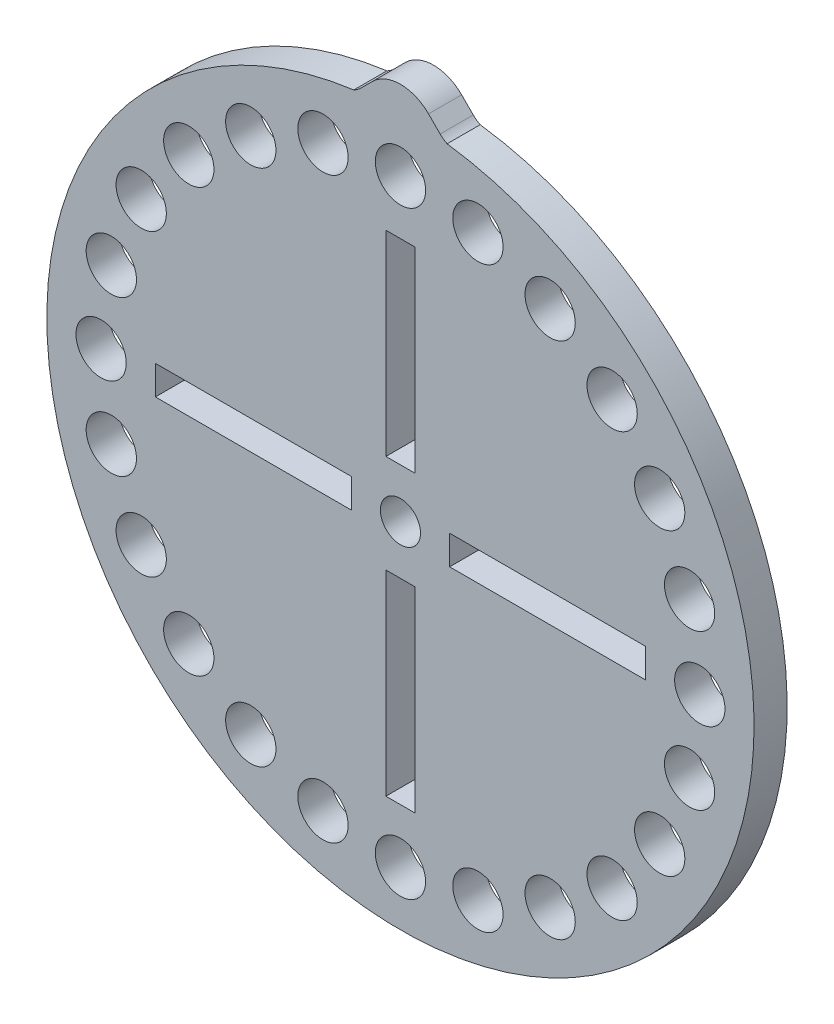
from build123d import *

# Parameters (mm, degrees)
SKETCH1_R             = 33.8
SKETCH1_R_2           = 2.54
SKETCH1_R_3           = 2.05
SKETCH1_W             = 3.048
SKETCH1_H             = 19.05
SKETCH1_W_2           = 19.05
SKETCH1_H_2           = 3.048
BOSS_EXTRUDE1_DEPTH   = 3.175
BOSS_EXTRUDE2_DEPTH   = 3.175
FILLET1_R             = 2.54
SKETCH4_R             = 33.927
SKETCH4_R_2           = 2.413
SKETCH4_R_3           = 1.923
SKETCH4_W             = 2.794
SKETCH4_H             = 18.796
SKETCH4_W_2           = 18.796
SKETCH4_H_2           = 2.794
KERF_ADJUSTMENT_DEPTH = 3.175


with BuildPart() as part:
    # Sketch1 → Boss-Extrude1 (new body)
    with BuildSketch(Plane.XY):
        Circle(SKETCH1_R)
        with Locations((14.36, 24.872249597)):
            Circle(SKETCH1_R_2, mode=Mode.SUBTRACT)
        with Locations((20.308106756, 20.308106756)):
            Circle(SKETCH1_R_2, mode=Mode.SUBTRACT)
        with Locations((24.872249597, 14.36)):
            Circle(SKETCH1_R_2, mode=Mode.SUBTRACT)
        with Locations((27.741389731, 7.433282975)):
            Circle(SKETCH1_R_2, mode=Mode.SUBTRACT)
        with Locations((28.72, 0)):
            Circle(SKETCH1_R_2, mode=Mode.SUBTRACT)
        with Locations((27.741389731, -7.433282975)):
            Circle(SKETCH1_R_2, mode=Mode.SUBTRACT)
        with Locations((24.872249597, -14.36)):
            Circle(SKETCH1_R_2, mode=Mode.SUBTRACT)
        with Locations((20.308106756, -20.308106756)):
            Circle(SKETCH1_R_2, mode=Mode.SUBTRACT)
        with Locations((14.36, -24.872249597)):
            Circle(SKETCH1_R_2, mode=Mode.SUBTRACT)
        with Locations((7.433282975, -27.741389731)):
            Circle(SKETCH1_R_2, mode=Mode.SUBTRACT)
        with Locations((0, -28.72)):
            Circle(SKETCH1_R_2, mode=Mode.SUBTRACT)
        with Locations((-7.433282975, -27.741389731)):
            Circle(SKETCH1_R_2, mode=Mode.SUBTRACT)
        with Locations((-14.36, -24.872249597)):
            Circle(SKETCH1_R_2, mode=Mode.SUBTRACT)
        with Locations((-20.308106756, -20.308106756)):
            Circle(SKETCH1_R_2, mode=Mode.SUBTRACT)
        with Locations((-24.872249597, -14.36)):
            Circle(SKETCH1_R_2, mode=Mode.SUBTRACT)
        with Locations((-27.741389731, -7.433282975)):
            Circle(SKETCH1_R_2, mode=Mode.SUBTRACT)
        with Locations((-28.72, 0)):
            Circle(SKETCH1_R_2, mode=Mode.SUBTRACT)
        with Locations((-27.741389731, 7.433282975)):
            Circle(SKETCH1_R_2, mode=Mode.SUBTRACT)
        with Locations((-24.872249597, 14.36)):
            Circle(SKETCH1_R_2, mode=Mode.SUBTRACT)
        with Locations((-20.308106756, 20.308106756)):
            Circle(SKETCH1_R_2, mode=Mode.SUBTRACT)
        with Locations((-14.36, 24.872249597)):
            Circle(SKETCH1_R_2, mode=Mode.SUBTRACT)
        with Locations((-7.433282975, 27.741389731)):
            Circle(SKETCH1_R_2, mode=Mode.SUBTRACT)
        with Locations((0, 28.72)):
            Circle(SKETCH1_R_2, mode=Mode.SUBTRACT)
        with Locations((7.433282975, 27.741389731)):
            Circle(SKETCH1_R_2, mode=Mode.SUBTRACT)
        Circle(SKETCH1_R_3, mode=Mode.SUBTRACT)
        with Locations((0, 14.115)):
            Rectangle(SKETCH1_W, SKETCH1_H, mode=Mode.SUBTRACT)
        with Locations((14.115, 0)):
            Rectangle(SKETCH1_W_2, SKETCH1_H_2, mode=Mode.SUBTRACT)
        with Locations((0, -14.115)):
            Rectangle(SKETCH1_W, SKETCH1_H, mode=Mode.SUBTRACT)
        with Locations((-14.115, 0)):
            Rectangle(SKETCH1_W_2, SKETCH1_H_2, mode=Mode.SUBTRACT)
    extrude(amount=BOSS_EXTRUDE1_DEPTH)

    # Sketch3 → Boss-Extrude2 (add)
    with BuildSketch(Plane.XY):
        with BuildLine():
            Line((-2.694076836, 35.224076836), (-4.406640425, 33.511513248))
            ThreePointArc((-4.406640425, 33.511513248), (0, 33.8), (4.406640425, 33.511513248))
            Line((4.406640425, 33.511513248), (2.694076836, 35.224076836))
            ThreePointArc((2.694076836, 35.224076836), (0, 36.34), (-2.694076836, 35.224076836))
        make_face()
    extrude(amount=BOSS_EXTRUDE2_DEPTH)

    # Fillet1
    fillet1_edges = [part.edges().sort_by_distance(p)[0] for p in [
        (-4.406640425, 33.511513248, 1.5875),
        (4.406640425, 33.511513248, 1.5875),
    ]]
    fillet(fillet1_edges, radius=FILLET1_R)

    # Sketch4 → Kerf Adjustment (add)
    with BuildSketch(Plane.XY):
        Circle(SKETCH4_R)
        with Locations((28.72, 0)):
            Circle(SKETCH4_R_2, mode=Mode.SUBTRACT)
        with Locations((27.741389731, 7.433282975)):
            Circle(SKETCH4_R_2, mode=Mode.SUBTRACT)
        with Locations((24.872249597, 14.36)):
            Circle(SKETCH4_R_2, mode=Mode.SUBTRACT)
        with Locations((20.308106756, 20.308106756)):
            Circle(SKETCH4_R_2, mode=Mode.SUBTRACT)
        with Locations((-14.36, -24.872249597)):
            Circle(SKETCH4_R_2, mode=Mode.SUBTRACT)
        with Locations((-7.433282975, -27.741389731)):
            Circle(SKETCH4_R_2, mode=Mode.SUBTRACT)
        with Locations((0, -28.72)):
            Circle(SKETCH4_R_2, mode=Mode.SUBTRACT)
        with Locations((7.433282975, -27.741389731)):
            Circle(SKETCH4_R_2, mode=Mode.SUBTRACT)
        with Locations((14.36, -24.872249597)):
            Circle(SKETCH4_R_2, mode=Mode.SUBTRACT)
        with Locations((20.308106756, -20.308106756)):
            Circle(SKETCH4_R_2, mode=Mode.SUBTRACT)
        with Locations((24.872249597, -14.36)):
            Circle(SKETCH4_R_2, mode=Mode.SUBTRACT)
        with Locations((27.741389731, -7.433282975)):
            Circle(SKETCH4_R_2, mode=Mode.SUBTRACT)
        with Locations((-14.36, 24.872249597)):
            Circle(SKETCH4_R_2, mode=Mode.SUBTRACT)
        with Locations((-20.308106756, 20.308106756)):
            Circle(SKETCH4_R_2, mode=Mode.SUBTRACT)
        with Locations((-24.872249597, 14.36)):
            Circle(SKETCH4_R_2, mode=Mode.SUBTRACT)
        with Locations((-27.741389731, 7.433282975)):
            Circle(SKETCH4_R_2, mode=Mode.SUBTRACT)
        with Locations((-28.72, 0)):
            Circle(SKETCH4_R_2, mode=Mode.SUBTRACT)
        with Locations((-27.741389731, -7.433282975)):
            Circle(SKETCH4_R_2, mode=Mode.SUBTRACT)
        with Locations((-24.872249597, -14.36)):
            Circle(SKETCH4_R_2, mode=Mode.SUBTRACT)
        with Locations((-20.308106756, -20.308106756)):
            Circle(SKETCH4_R_2, mode=Mode.SUBTRACT)
        Circle(SKETCH4_R_3, mode=Mode.SUBTRACT)
        with Locations((7.433282975, 27.741389731)):
            Circle(SKETCH4_R_2, mode=Mode.SUBTRACT)
        with Locations((0, 28.72)):
            Circle(SKETCH4_R_2, mode=Mode.SUBTRACT)
        with Locations((-7.433282975, 27.741389731)):
            Circle(SKETCH4_R_2, mode=Mode.SUBTRACT)
        with Locations((14.36, 24.872249597)):
            Circle(SKETCH4_R_2, mode=Mode.SUBTRACT)
        with Locations((0, -14.115)):
            Rectangle(SKETCH4_W, SKETCH4_H, mode=Mode.SUBTRACT)
        with Locations((14.115, 0)):
            Rectangle(SKETCH4_W_2, SKETCH4_H_2, mode=Mode.SUBTRACT)
        with Locations((0, 14.115)):
            Rectangle(SKETCH4_W, SKETCH4_H, mode=Mode.SUBTRACT)
        with Locations((-14.115, 0)):
            Rectangle(SKETCH4_W_2, SKETCH4_H_2, mode=Mode.SUBTRACT)
    extrude(amount=KERF_ADJUSTMENT_DEPTH)


solid = part.part
